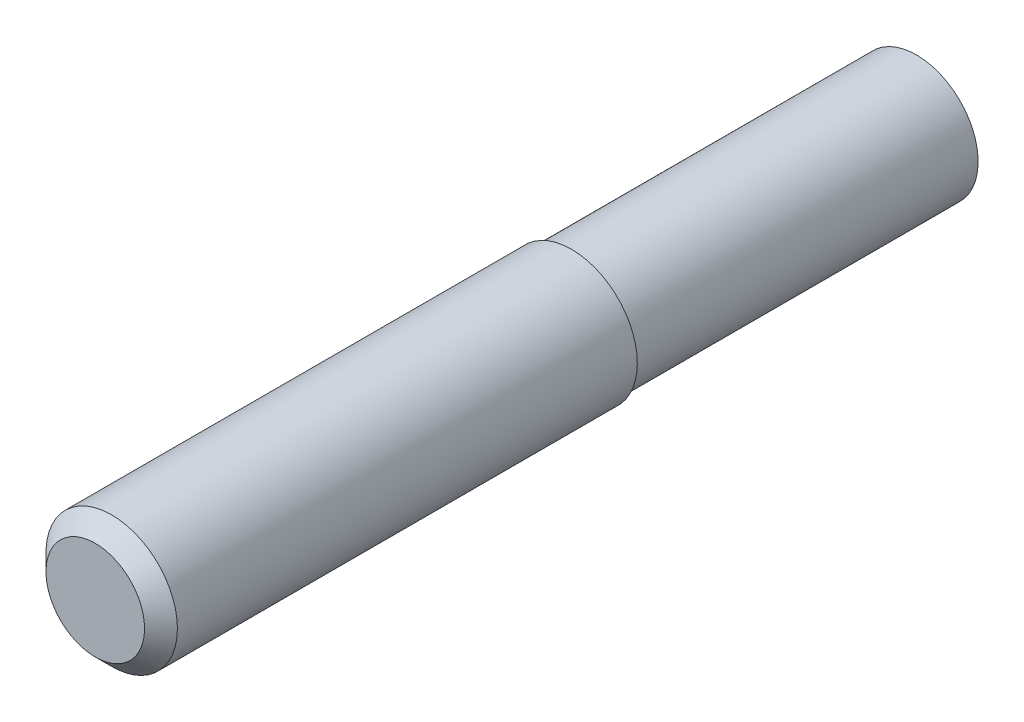
from build123d import *

# Parameters (mm, degrees)
SKIZZE1_R                       = 10
AUFSATZ_LINEAR_AUSTRAGEN1_DEPTH = 100
SKIZZE2_R                       = 10
SKIZZE2_R_2                     = 8
SCHNITT_LINEAR_AUSTRAGEN1_DEPTH = 68
FASE1_SIZE                      = 2
SKIZZE3_R                       = 10
SKIZZE3_R_2                     = 7.5
SCHNITT_LINEAR_AUSTRAGEN2_DEPTH = 42


with BuildPart() as part:
    # Skizze1 → Aufsatz-Linear austragen1 (new body)
    with BuildSketch(Plane.XY):
        Circle(SKIZZE1_R)
    extrude(amount=AUFSATZ_LINEAR_AUSTRAGEN1_DEPTH)

    # Skizze2 → Schnitt-Linear austragen1 (cut)
    with BuildSketch(Plane.XY.offset(100)):
        Circle(SKIZZE2_R)
        Circle(SKIZZE2_R_2, mode=Mode.SUBTRACT)
    extrude(amount=-SCHNITT_LINEAR_AUSTRAGEN1_DEPTH, mode=Mode.SUBTRACT)

    # Fase1
    fase1_edges = [part.edges().sort_by_distance(p)[0] for p in [
        (-8, 0, 100),
    ]]
    chamfer(fase1_edges, length=FASE1_SIZE)

    # Skizze3 → Schnitt-Linear austragen2 (cut)
    with BuildSketch(Plane(origin=(0, 0, 0), x_dir=(-1, 0, 0), z_dir=(0, 0, -1))):
        Circle(SKIZZE3_R)
        Circle(SKIZZE3_R_2, mode=Mode.SUBTRACT)
    extrude(amount=-SCHNITT_LINEAR_AUSTRAGEN2_DEPTH, mode=Mode.SUBTRACT)


solid = part.part
